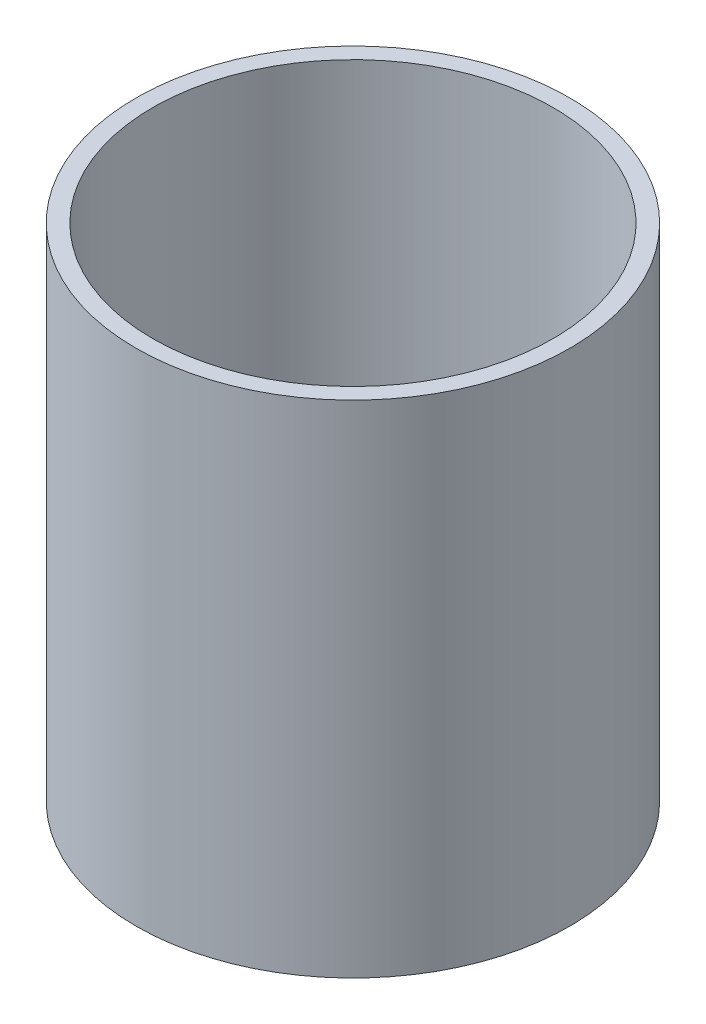
from build123d import *

# Parameters (mm, degrees)
SKETCH_1_R         = 26
SKETCH_1_R_2       = 24
EXTRUDE_1_DEPTH    = 70
SKETCH1_R          = 26
CUT_EXTRUDE1_DEPTH = 10


with BuildPart() as part:
    # 草图1 → 凸台-拉伸1 (new body)
    with BuildSketch(Plane(origin=(0, 0, 0), x_dir=(1, 0, 0), z_dir=(0, 1, 0))):
        Circle(SKETCH_1_R)
        Circle(SKETCH_1_R_2, mode=Mode.SUBTRACT)
    extrude(amount=EXTRUDE_1_DEPTH)

    # Sketch1 → Cut-Extrude1 (cut)
    with BuildSketch(Plane(origin=(0, 70, 0), x_dir=(1, 0, 0), z_dir=(0, 1, 0))):
        Circle(SKETCH1_R)
    extrude(amount=-CUT_EXTRUDE1_DEPTH, mode=Mode.SUBTRACT)


solid = part.part
